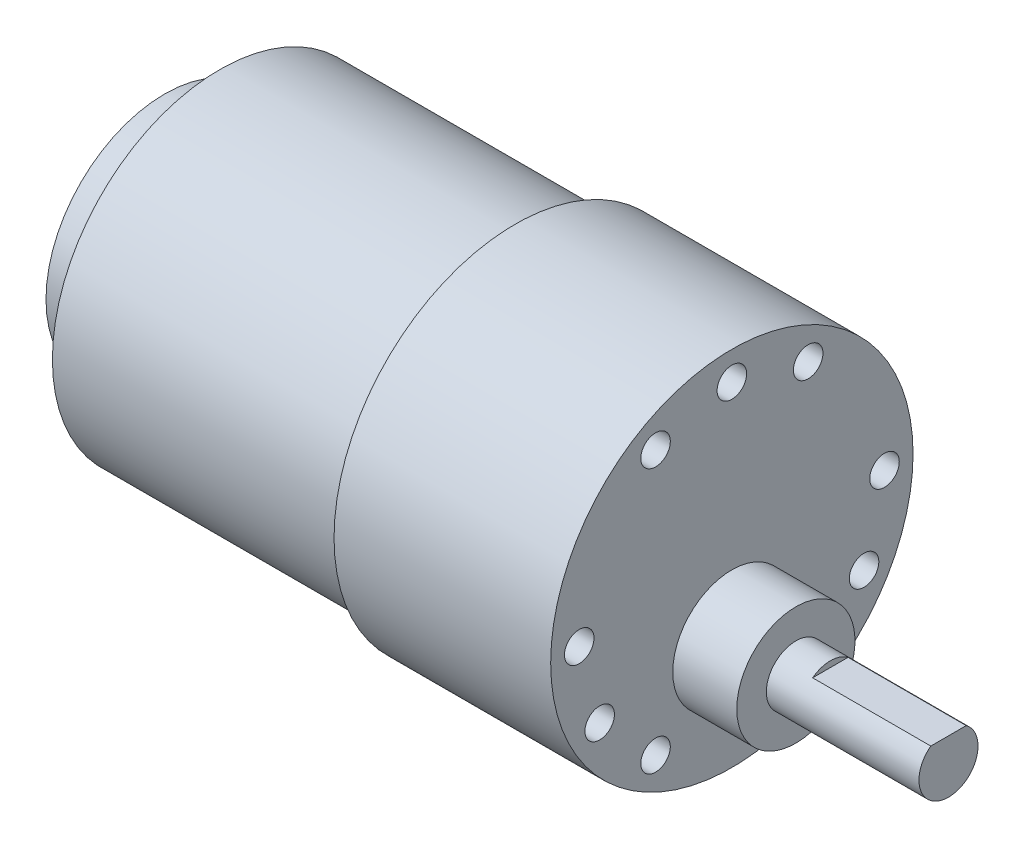
from build123d import *

# Parameters (mm, degrees)
ENL_V_MAT_EXTRU_1_DEPTH      = 10
ENL_V_MAT_EXTRU_1_DEPTH_BACK = 10
ESQUISSE4_W                  = 18.656759262
ESQUISSE4_H                  = 11.470185
ESQUISSE5_R                  = 12.05
ESQUISSE5_R_2                = 11.9
BOSS_EXTRU_1_DEPTH           = 5.6
ESQUISSE6_R                  = 1.5
ENL_V_MAT_EXTRU_2_DEPTH      = 5
R_P_TITION_CIRCULAIRE1_COUNT = 3


with BuildPart() as part:
    # Esquisse1 → Révolution1 (revolve)
    with BuildSketch(Plane.XY):
        Polygon((-30, 0), (-30, 17), (0, 17), (0, 18.4), (22, 18.4), (22, 0), align=None)
    revolve(axis=Axis((-59.117838542, 0, 0), (1, 0, 0)))

    # Esquisse3 → Révolution2 (revolve)
    with BuildSketch(Plane.XY):
        Polygon((22, -1), (28.5, -1), (28.5, -4), (44, -4), (44, -7), (22, -7), align=None)
    revolve(axis=Axis((8.410725031, -7, 0), (1, 0, 0)))

    # Esquisse4 → Enlèv. mat.-Extru.1 (cut, two sides: drawn at the far end of the back side and taken through both)
    with BuildSketch(Plane.XY.offset(-ENL_V_MAT_EXTRU_1_DEPTH_BACK)):
        with Locations((41.328379631, 1.1350925)):
            Rectangle(ESQUISSE4_W, ESQUISSE4_H)
    extrude(amount=ENL_V_MAT_EXTRU_1_DEPTH + ENL_V_MAT_EXTRU_1_DEPTH_BACK, mode=Mode.SUBTRACT)

    # Esquisse5 → Boss.-Extru.1 (add)
    with BuildSketch(Plane.ZY.offset(30)):
        Circle(ESQUISSE5_R)
        Circle(ESQUISSE5_R_2, mode=Mode.SUBTRACT)
    extrude(amount=BOSS_EXTRU_1_DEPTH)

    # Esquisse6 → Enlèv. mat.-Extru.2 (cut)
    with BuildSketch(Plane(origin=(22, 0, 0), x_dir=(0, 0, -1), z_dir=(1, 0, 0))):
        with Locations((0, 15.5)):
            Circle(ESQUISSE6_R)
        with Locations((7.75, 13.423393759)):
            Circle(ESQUISSE6_R)
        with Locations((-7.75, 13.423393759)):
            Circle(ESQUISSE6_R)
    enl_v_mat_extru_2 = extrude(amount=-ENL_V_MAT_EXTRU_2_DEPTH, mode=Mode.SUBTRACT)

    # Répétition circulaire1: Enlèv. mat.-Extru.2 ×3 about axis
    r_p_tition_circulaire1_axis = Axis((22, 0, 0), (-1, 0, 0))
    for i in range(1, R_P_TITION_CIRCULAIRE1_COUNT):
        add(enl_v_mat_extru_2.rotate(r_p_tition_circulaire1_axis, i * 360 / R_P_TITION_CIRCULAIRE1_COUNT), mode=Mode.SUBTRACT)


solid = part.part
